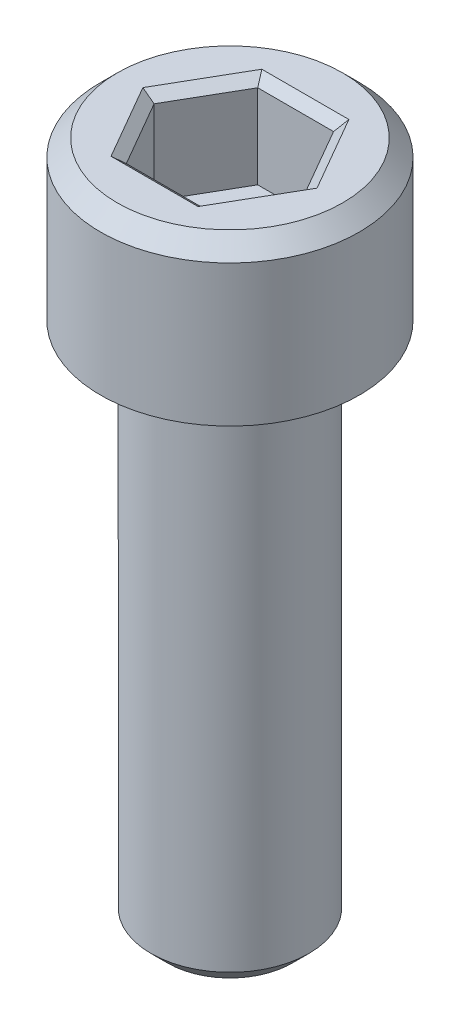
from build123d import *

# Parameters (mm, degrees)
EXTRUDE1_DEPTH = 2.794
CHAMFER1_SIZE  = 0.508
CHAMFER2_SIZE  = 0.29329394
CHAMFER2_SIZE2 = 0.253999961


with BuildPart() as part:
    # Sketch1 → Revolve1 (revolve)
    with BuildSketch(Plane.XY):
        Polygon((0, 0), (0, 20.6502), (-3.9116, 20.6502), (-3.9116, 15.875), (-2.3876, 15.875), (-2.3876, 0), align=None)
    revolve(axis=Axis((0, 0, 0), (0, 1, 0)))

    # Sketch2 → Extrude1 (cut)
    with BuildSketch(Plane(origin=(0, 20.6502, 0), x_dir=(1, 0, 0), z_dir=(0, 1, 0))):
        Polygon((2.2913594, 0), (1.1456797, 1.98437545), (-1.1456797, 1.98437545), (-2.2913594, 0), (-1.1456797, -1.98437545), (1.1456797, -1.98437545), align=None)
    extrude(amount=-EXTRUDE1_DEPTH, mode=Mode.SUBTRACT)

    # Chamfer1
    chamfer1_edges = [part.edges().sort_by_distance(p)[0] for p in [
        (2.3876, 0, 0),
        (3.9116, 20.6502, 0),
    ]]
    chamfer(chamfer1_edges, length=CHAMFER1_SIZE)

    # Chamfer2
    chamfer2_edges = [part.edges().sort_by_distance(p)[0] for p in [
        (1.71851955, 20.6502, 0.992187725),
        (1.71851955, 20.6502, -0.992187725),
        (0, 20.6502, -1.98437545),
        (-1.71851955, 20.6502, -0.992187725),
        (-1.71851955, 20.6502, 0.992187725),
        (0, 20.6502, 1.98437545),
    ]]
    chamfer2_side = [part.faces().sort_by_distance(p)[0] for p in [
        (3.307331654, 20.6502, 0),
    ]]
    chamfer(chamfer2_edges, length=CHAMFER2_SIZE, length2=CHAMFER2_SIZE2, reference=chamfer2_side[0])


solid = part.part
